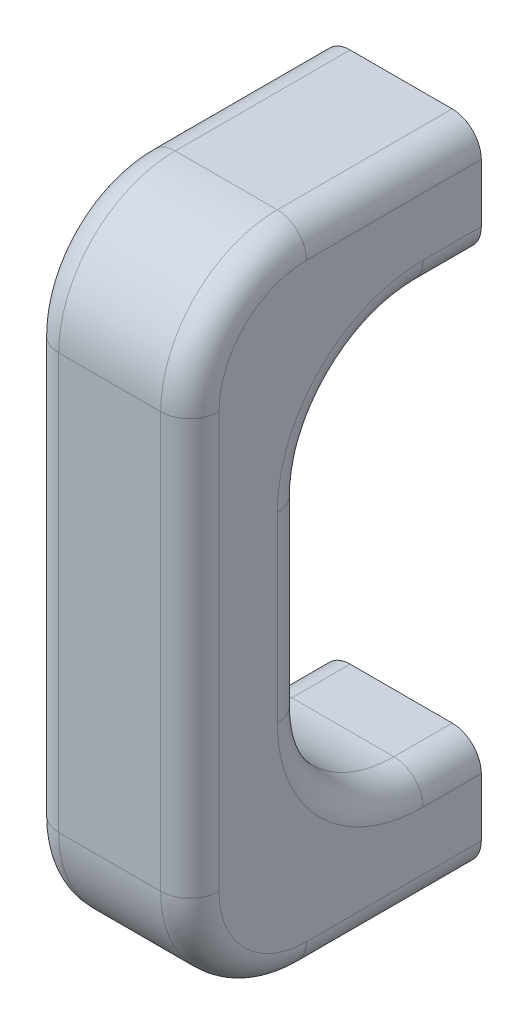
from build123d import *

# Parameters (mm, degrees)
ESQUISSE1_W             = 11
ESQUISSE1_H             = 44.5
BOSS_EXTRU_1_DEPTH      = 20
CONG_1_R                = 8
ESQUISSE2_W             = 11.999855804
ESQUISSE2_H             = 28.501098838
ENL_V_MAT_EXTRU_1_DEPTH = 20
CONG_2_R                = 8
ESQUISSE3_R             = 1.5
ENL_V_MAT_EXTRU_2_DEPTH = 7
CONG_3_R                = 2


with BuildPart() as part:
    # Esquisse1 → Boss.-Extru.1 (new body)
    with BuildSketch(Plane.XY):
        Rectangle(ESQUISSE1_W, ESQUISSE1_H)
    extrude(amount=BOSS_EXTRU_1_DEPTH)

    # Congé1
    cong_1_edges = [part.edges().sort_by_distance(p)[0] for p in [
        (0, -22.25, 20),
        (0, 22.25, 20),
    ]]
    fillet(cong_1_edges, radius=CONG_1_R)

    # Esquisse2 → Enlèv. mat.-Extru.1 (cut)
    with BuildSketch(Plane(origin=(5.5, 0, 0), x_dir=(0, 0, -1), z_dir=(1, 0, 0))):
        with Locations((-5.999927902, 0)):
            Rectangle(ESQUISSE2_W, ESQUISSE2_H)
    extrude(amount=-ENL_V_MAT_EXTRU_1_DEPTH, mode=Mode.SUBTRACT)

    # Congé2
    cong_2_edges = [part.edges().sort_by_distance(p)[0] for p in [
        (0, -14.250549419, 11.999855804),
        (0, 14.250549419, 11.999855804),
    ]]
    fillet(cong_2_edges, radius=CONG_2_R)

    # Esquisse3 → Enlèv. mat.-Extru.2 (cut)
    with BuildSketch(Plane(origin=(0, 0, 0), x_dir=(-1, 0, 0), z_dir=(0, 0, -1))):
        with Locations((0, 18.25027471)):
            Circle(ESQUISSE3_R)
        with Locations((0, -18.25027471)):
            Circle(ESQUISSE3_R)
    extrude(amount=-ENL_V_MAT_EXTRU_2_DEPTH, mode=Mode.SUBTRACT)

    # Congé3
    cong_3_edges = [part.edges().sort_by_distance(p)[0] for p in [
        (5.5, 0, 20),
        (-5.5, 0, 20),
        (5.5, 22.25, 6),
        (5.5, -22.25, 6),
        (5.5, 19.906854249, 17.656854249),
        (5.5, -19.906854249, 17.656854249),
        (-5.5, -22.25, 6),
        (-5.5, 22.25, 6),
        (-5.5, 19.906854249, 17.656854249),
        (-5.5, -19.906854249, 17.656854249),
        (-5.5, 14.250549419, 1.999927902),
        (5.5, 14.250549419, 1.999927902),
        (5.5, -14.250549419, 1.999927902),
        (-5.5, -14.250549419, 1.999927902),
        (5.5, 0, 11.999855804),
        (-5.5, 0, 11.999855804),
        (5.5, -11.907403669, 9.656710053),
        (-5.5, -11.907403669, 9.656710053),
        (5.5, 11.907403669, 9.656710053),
        (-5.5, 11.907403669, 9.656710053),
    ]]
    fillet(cong_3_edges, radius=CONG_3_R)


solid = part.part
